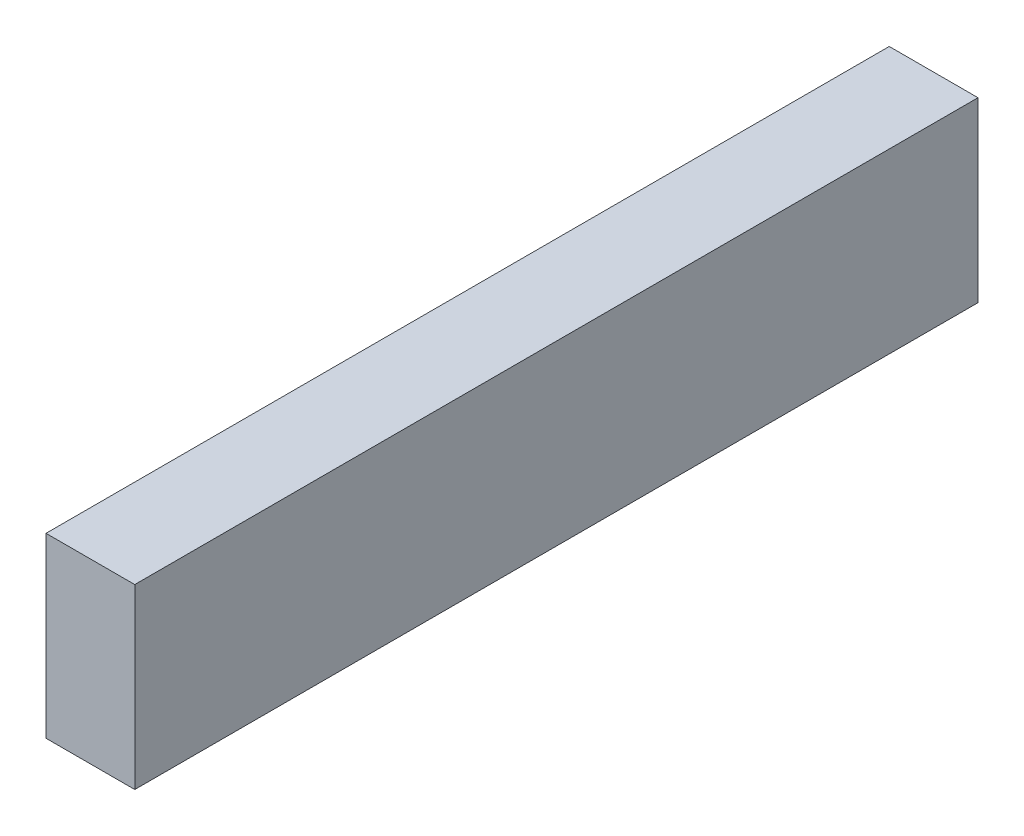
from build123d import *

# Parameters (mm, degrees)
SKETCH1_W           = 10
SKETCH1_H           = 95
BOSS_EXTRUDE1_DEPTH = 20


with BuildPart() as part:
    # Sketch1 → Boss-Extrude1 (new body)
    with BuildSketch(Plane.XZ.offset(-3)):
        with Locations((137.5, -27.5)):
            Rectangle(SKETCH1_W, SKETCH1_H)
    extrude(amount=BOSS_EXTRUDE1_DEPTH)


solid = part.part
